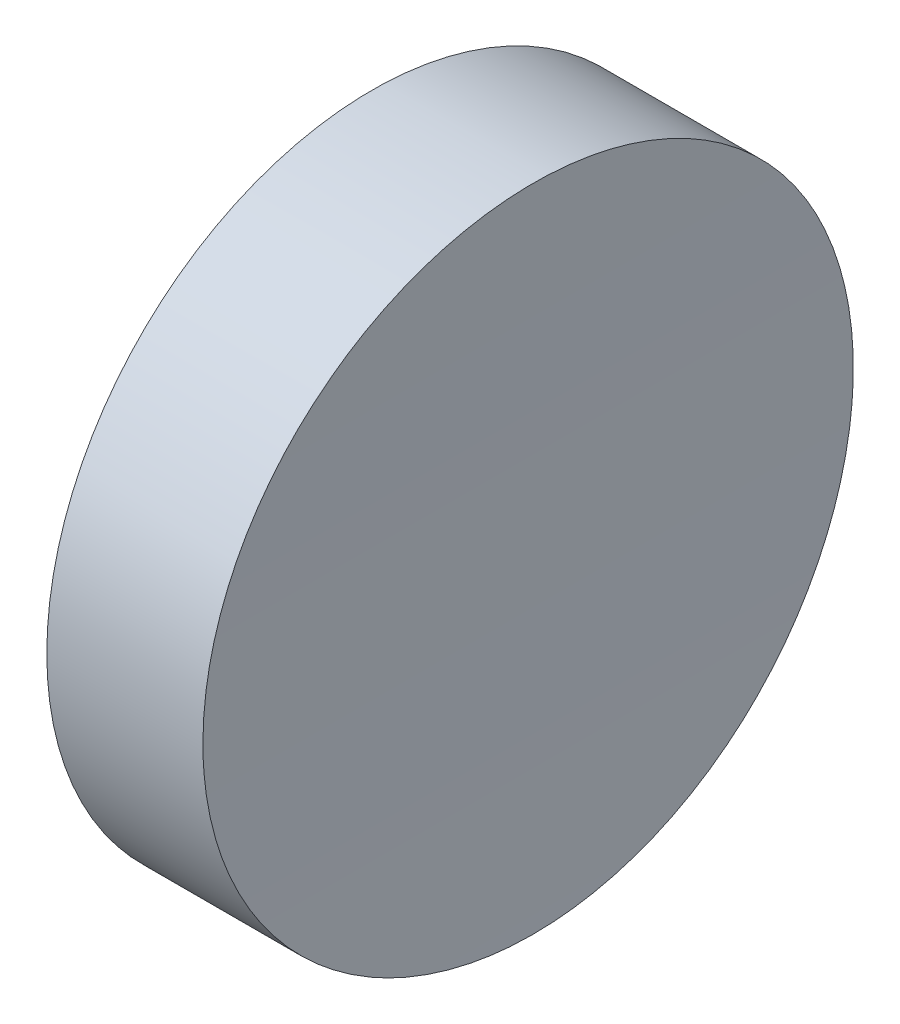
from build123d import *

# Parameters (mm, degrees)
SKETCH_1_R               = 12.5
EXTRUDE_1_DEPTH          = 10
SKETCH_2_R               = 400
CUT_EXTRUDE_1_DEPTH      = 13.5
CUT_EXTRUDE_1_DEPTH_BACK = 13.5


with BuildPart() as part:
    # 草图1 → 凸台-拉伸1 (new body)
    with BuildSketch(Plane(origin=(0, 0, 0), x_dir=(0, 0, -1), z_dir=(1, 0, 0))):
        Circle(SKETCH_1_R)
    extrude(amount=EXTRUDE_1_DEPTH)

    # 草图2 → 切除-拉伸1 (cut, two sides)
    with BuildSketch(Plane.XY) as cut_extrude_1_sk:
        with Locations((406, 0)):
            Circle(SKETCH_2_R)
    extrude(amount=CUT_EXTRUDE_1_DEPTH, mode=Mode.SUBTRACT)
    extrude(cut_extrude_1_sk.sketch, amount=-CUT_EXTRUDE_1_DEPTH_BACK, mode=Mode.SUBTRACT)


solid = part.part
